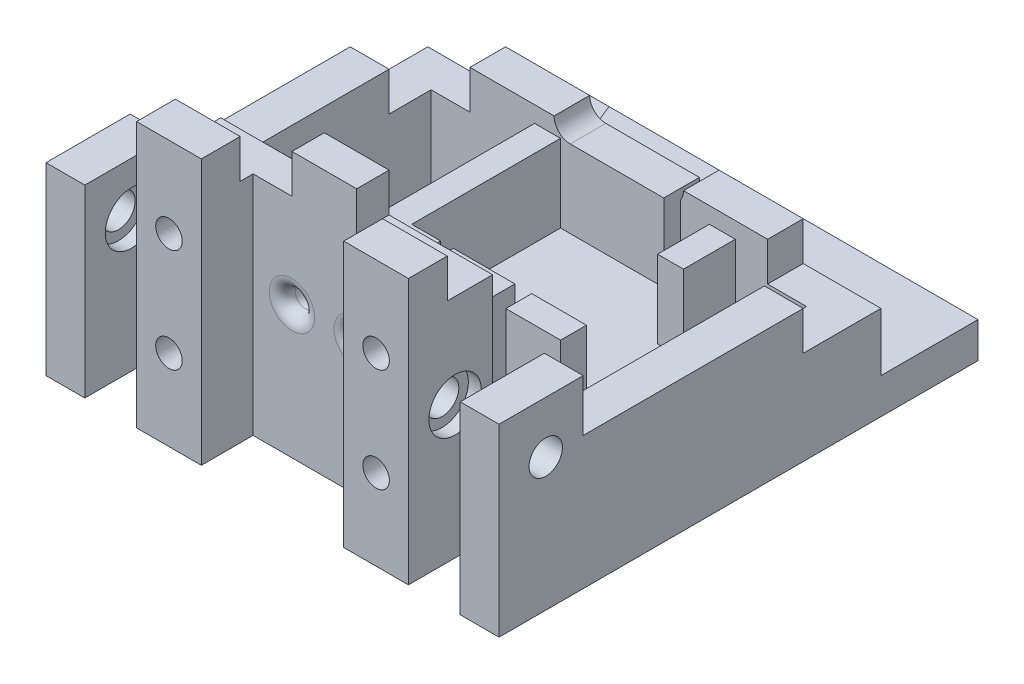
from build123d import *

# Parameters (mm, degrees)
BOSS_EXTRUDE1_DEPTH  = 20.5
SKETCH5_W            = 23
SKETCH5_H            = 23
BOSS_EXTRUDE3_DEPTH  = 6
BOSS_EXTRUDE6_DEPTH  = 18
SKETCH18_W           = 2.6
SKETCH18_H           = 4
SKETCH18_W_2         = 2
SKETCH18_W_3         = 4
SKETCH18_H_2         = 15
SKETCH18_H_3         = 5.5
CUT_EXTRUDE10_DEPTH  = 14.5
SKETCH8_W            = 6
SKETCH8_H            = 13
BOSS_EXTRUDE4_DEPTH  = 8
SKETCH7_R            = 2.575
CUT_EXTRUDE_X_DEPTH  = 6
SKETCH9_R            = 4.05
CUT_EXTRUDE4_DEPTH   = 2
SKETCH10_W           = 29
SKETCH10_H           = 13
BOSS_EXTRUDE5_DEPTH  = 28.5
SKETCH12_W           = 8
SKETCH12_H           = 13
CUT_EXTRUDE6_DEPTH   = 24
SKETCH13_R           = 2.575
CUT_EXTRUDE7_DEPTH   = 6
SKETCH14_R           = 4.05
CUT_EXTRUDE8_DEPTH   = 2
CUT_EXTRUDE21_REACH  = 61
SKETCH35_R           = 1.5
CUT_EXTRUDE22_REACH  = 30.5
FILLET1_R            = 2
BOSS_EXTRUDE7_DEPTH  = 12.5
SKETCH34_R           = 2.05
CUT_EXTRUDE20_DEPTH  = 10
SKETCH38_W           = 70
SKETCH38_H           = 5.5
BOSS_EXTRUDE8_DEPTH  = 15
BOSS_EXTRUDE9_DEPTH  = 7.5
CUT_EXTRUDE23_START  = -5.5
CUT_EXTRUDE23_DEPTH  = 5.5
BOSS_EXTRUDE10_DEPTH = 58
CUT_EXTRUDE24_REACH  = 76
SKETCH42_W           = 8
SKETCH42_H           = 4.5
BOSS_EXTRUDE11_START = -14
SKETCH43_W           = 10
SKETCH43_H           = 5
BOSS_EXTRUDE11_DEPTH = 42
BOSS_EXTRUDE12_REACH = 22
SKETCH44_W           = 42
SKETCH44_H           = 5
SKETCH45_W           = 12
SKETCH45_H           = 12
CUT_EXTRUDE25_DEPTH  = 6
CUT_EXTRUDE26_DEPTH  = 6


with BuildPart() as part:
    # Sketch1 → Boss-Extrude1 (new body)
    with BuildSketch(Plane(origin=(0, 0, 0), x_dir=(1, 0, 0), z_dir=(0, 1, 0))):
        Polygon((-29, 24), (-29, -29.5), (-35, -29.5), (-35, 29.5), (35, 29.5), (35, -29.5), (29, -29.5), (29, 24), align=None)
    extrude(amount=-BOSS_EXTRUDE1_DEPTH)



with BuildPart() as body_2:
    # Sketch5 → Boss-Extrude3 (new body)
    with BuildSketch(Plane(origin=(0, -20.5, 0), x_dir=(1, 0, 0), z_dir=(0, 1, 0))):
        with Locations((2.5, 12.5)):
            Rectangle(SKETCH5_W, SKETCH5_H)
    extrude(amount=BOSS_EXTRUDE3_DEPTH)


with BuildPart() as part_1:
    add(part.part)

    add(body_2.part)  # Boss-Extrude6 merges body 2
    # Sketch16 → Boss-Extrude6 (add)
    with BuildSketch(Plane.XZ.offset(20.5)):
        Polygon((18, -24), (14, -24), (14, -1), (-9, -1), (-9, -24), (-13, -24), (-13, 3), (18, 3), align=None)
    extrude(amount=-BOSS_EXTRUDE6_DEPTH)

    # Sketch18 → Cut-Extrude10 (cut)
    with BuildSketch(Plane(origin=(0, 0, 0), x_dir=(1, 0, 0), z_dir=(0, 1, 0))):
        with Locations((8.25, -1)):
            Rectangle(SKETCH18_W, SKETCH18_H)
        with Locations((-3.55, -1)):
            Rectangle(SKETCH18_W_2, SKETCH18_H)
        with Locations((16, 8.5)):
            Rectangle(SKETCH18_W_3, SKETCH18_H_2)
        with Locations((8.25, 26.75)):
            Rectangle(SKETCH18_W, SKETCH18_H_3)
    extrude(amount=-CUT_EXTRUDE10_DEPTH, mode=Mode.SUBTRACT)

    # Sketch8 → Boss-Extrude4 (add)
    with BuildSketch(Plane(origin=(0, 0, 0), x_dir=(1, 0, 0), z_dir=(0, 1, 0))):
        with Locations((32, -23)):
            Rectangle(SKETCH8_W, SKETCH8_H)
    boss_extrude4 = extrude(amount=BOSS_EXTRUDE4_DEPTH)

    # Sketch7 → Cut-Extrude x (cut)
    with BuildSketch(Plane(origin=(35, 0, 0), x_dir=(0, 0, -1), z_dir=(1, 0, 0))):
        with Locations((-22.291637032, 0)):
            Circle(SKETCH7_R)
    cut_extrude_x = extrude(amount=-CUT_EXTRUDE_X_DEPTH, mode=Mode.SUBTRACT)

    # Sketch9 → Cut-Extrude4 (cut)
    with BuildSketch(Plane(origin=(29, 0, 0), x_dir=(0, 0, -1), z_dir=(1, 0, 0))):
        with Locations((-22.291637032, 0)):
            Circle(SKETCH9_R)
    cut_extrude4 = extrude(amount=CUT_EXTRUDE4_DEPTH, mode=Mode.SUBTRACT)

    # Sketch10 → Boss-Extrude5 (add)
    with BuildSketch(Plane.XZ.offset(20.5)):
        with Locations((14.5, 23)):
            Rectangle(SKETCH10_W, SKETCH10_H)
    boss_extrude5 = extrude(amount=-BOSS_EXTRUDE5_DEPTH)

    # Sketch12 → Cut-Extrude6 (cut)
    with BuildSketch(Plane(origin=(0, 8, 0), x_dir=(1, 0, 0), z_dir=(0, 1, 0))):
        with Locations((25, -23)):
            Rectangle(SKETCH12_W, SKETCH12_H)
    cut_extrude6 = extrude(amount=-CUT_EXTRUDE6_DEPTH, mode=Mode.SUBTRACT)

    # Sketch13 → Cut-Extrude7 (cut)
    with BuildSketch(Plane(origin=(21, 0, 0), x_dir=(0, 0, -1), z_dir=(1, 0, 0))):
        with Locations((-22.291637032, 0)):
            Circle(SKETCH13_R)
    cut_extrude7 = extrude(amount=-CUT_EXTRUDE7_DEPTH, mode=Mode.SUBTRACT)

    # Sketch14 → Cut-Extrude8 (cut)
    with BuildSketch(Plane(origin=(21, 0, 0), x_dir=(0, 0, -1), z_dir=(1, 0, 0))):
        with Locations((-22.291637032, 0)):
            Circle(SKETCH14_R)
    cut_extrude8 = extrude(amount=-CUT_EXTRUDE8_DEPTH, mode=Mode.SUBTRACT)

    # Mirror1: Boss-Extrude4, Cut-Extrude x, Cut-Extrude4, Boss-Extrude5, Cut-Extrude6, Cut-Extrude7, Cut-Extrude8 across plane
    add(boss_extrude4.mirror(Plane(origin=(0, 0, 0), x_dir=(0, 0, 1), z_dir=(1, 0, 0))))
    add(cut_extrude_x.mirror(Plane(origin=(0, 0, 0), x_dir=(0, 0, 1), z_dir=(1, 0, 0))), mode=Mode.SUBTRACT)
    add(cut_extrude4.mirror(Plane(origin=(0, 0, 0), x_dir=(0, 0, 1), z_dir=(1, 0, 0))), mode=Mode.SUBTRACT)
    add(boss_extrude5.mirror(Plane(origin=(0, 0, 0), x_dir=(0, 0, 1), z_dir=(1, 0, 0))))
    add(cut_extrude6.mirror(Plane(origin=(0, 0, 0), x_dir=(0, 0, 1), z_dir=(1, 0, 0))), mode=Mode.SUBTRACT)
    add(cut_extrude7.mirror(Plane(origin=(0, 0, 0), x_dir=(0, 0, 1), z_dir=(1, 0, 0))), mode=Mode.SUBTRACT)
    add(cut_extrude8.mirror(Plane(origin=(0, 0, 0), x_dir=(0, 0, 1), z_dir=(1, 0, 0))), mode=Mode.SUBTRACT)

    # Sketch35 → Cut-Extrude21 (cut, up to next)
    with BuildSketch(Plane.XY.offset(29.5), mode=Mode.PRIVATE) as cut_extrude21_sk1:
        with Locations((-5, 0)):
            Circle(SKETCH35_R)
    cut_extrude21_tool1 = extrude(cut_extrude21_sk1.sketch, amount=-CUT_EXTRUDE21_REACH, mode=Mode.PRIVATE) & part_1.part
    add(cut_extrude21_tool1.solids().sort_by_distance((-5, 0, 29.5))[0], mode=Mode.SUBTRACT)
    # Sketch35 → Cut-Extrude21 (cut, up to next)
    with BuildSketch(Plane.XY.offset(29.5), mode=Mode.PRIVATE) as cut_extrude21_sk2:
        with Locations((5, 0)):
            Circle(SKETCH35_R)
    cut_extrude21_tool2 = extrude(cut_extrude21_sk2.sketch, amount=-CUT_EXTRUDE21_REACH, mode=Mode.PRIVATE) & part_1.part
    add(cut_extrude21_tool2.solids().sort_by_distance((5, 0, 29.5))[0], mode=Mode.SUBTRACT)

    # Sketch36 → Cut-Extrude22 (cut, up to next)
    with BuildSketch(Plane(origin=(0, 8, 0), x_dir=(1, 0, 0), z_dir=(0, 1, 0)), mode=Mode.PRIVATE) as cut_extrude22_sk1:
        Polygon((-5, -29.5), (5, -29.5), (11, -29.5), (11, -21.5), (-11, -21.5), (-11, -29.5), align=None)
    cut_extrude22_tool1 = extrude(cut_extrude22_sk1.sketch, amount=-CUT_EXTRUDE22_REACH, mode=Mode.PRIVATE) & part_1.part
    add(cut_extrude22_tool1.solids().sort_by_distance((0, 8, 25.5))[0], mode=Mode.SUBTRACT)

    # Fillet1
    fillet1_edges = [part_1.edges().sort_by_distance(p)[0] for p in [
        (-6.5, 0, 16.5),
        (3.5, 0, 16.5),
        (-6.5, 0, 21.5),
        (3.5, 0, 21.5),
    ]]
    fillet(fillet1_edges, radius=FILLET1_R)

    # Sketch37 → Boss-Extrude7 (add)
    with BuildSketch(Plane(origin=(0, 8, 0), x_dir=(1, 0, 0), z_dir=(0, 1, 0))):
        Polygon((-11, -21.5), (11, -21.5), (11, -29.5), (21, -29.5), (21, -16.5), (-21, -16.5), (-21, -29.5), (-11, -29.5), align=None)
    extrude(amount=BOSS_EXTRUDE7_DEPTH)

    # Sketch34 → Cut-Extrude20 (cut)
    with BuildSketch(Plane.XY.offset(29.5)):
        with Locations((16, -8)):
            Circle(SKETCH34_R)
        with Locations((16, 8)):
            Circle(SKETCH34_R)
        with Locations((-16, 8)):
            Circle(SKETCH34_R)
        with Locations((-16, -8)):
            Circle(SKETCH34_R)
    extrude(amount=-CUT_EXTRUDE20_DEPTH, mode=Mode.SUBTRACT)

    # Sketch38 → Boss-Extrude8 (add)
    with BuildSketch(Plane(origin=(0, 0, -29.5), x_dir=(-1, 0, 0), z_dir=(0, 0, -1))):
        with Locations((0, -17.75)):
            Rectangle(SKETCH38_W, SKETCH38_H)
    extrude(amount=BOSS_EXTRUDE8_DEPTH)

    # Sketch39 → Boss-Extrude9 (add)
    with BuildSketch(Plane(origin=(0, -15, 0), x_dir=(1, 0, 0), z_dir=(0, 1, 0))):
        Polygon((11.5, 29.5), (14.5, 37), (-14.5, 37), (-11.5, 29.5), align=None)
    extrude(amount=BOSS_EXTRUDE9_DEPTH)

    # Sketch40 → Cut-Extrude23 (cut)
    with BuildSketch(Plane(origin=(0, 0, -29.5), x_dir=(-1, 0, 0), z_dir=(0, 0, -1)).offset(CUT_EXTRUDE23_START)):
        with BuildLine():
            Line((-7.5, 2.5), (7.5, 2.5))
            ThreePointArc((7.5, 2.5), (10, 0), (7.5, -2.5))
            Line((7.5, -2.5), (-7.5, -2.5))
            ThreePointArc((-7.5, -2.5), (-10, 0), (-7.5, 2.5))
        make_face()
    extrude(amount=CUT_EXTRUDE23_DEPTH, mode=Mode.SUBTRACT)

    # Sketch41 → Boss-Extrude10 (add)
    with BuildSketch(Plane.ZY.offset(-29)):
        Polygon((-0.5, -20.5), (9.5, -20.5), (9.5, -17.5), (6.5, -15.5), (2.5, -15.5), (-0.5, -18.5), align=None)
    extrude(amount=BOSS_EXTRUDE10_DEPTH)

    # Sketch42 → Cut-Extrude24 (cut, up to next)
    with BuildSketch(Plane.XY.offset(29.5), mode=Mode.PRIVATE) as cut_extrude24_sk1:
        with Locations((25, -18.25)):
            Rectangle(SKETCH42_W, SKETCH42_H)
    cut_extrude24_tool1 = extrude(cut_extrude24_sk1.sketch, amount=-CUT_EXTRUDE24_REACH, mode=Mode.PRIVATE) & part_1.part
    add(cut_extrude24_tool1.solids().sort_by_distance((25, -18.25, 29.5))[0], mode=Mode.SUBTRACT)
    # Sketch42 → Cut-Extrude24 (cut, up to next)
    with BuildSketch(Plane.XY.offset(29.5), mode=Mode.PRIVATE) as cut_extrude24_sk2:
        with Locations((-25, -18.25)):
            Rectangle(SKETCH42_W, SKETCH42_H)
    cut_extrude24_tool2 = extrude(cut_extrude24_sk2.sketch, amount=-CUT_EXTRUDE24_REACH, mode=Mode.PRIVATE) & part_1.part
    add(cut_extrude24_tool2.solids().sort_by_distance((-25, -18.25, 29.5))[0], mode=Mode.SUBTRACT)

    # Sketch43 → Boss-Extrude11 (add)
    with BuildSketch(Plane(origin=(35, 0, 0), x_dir=(0, 0, -1), z_dir=(1, 0, 0)).offset(BOSS_EXTRUDE11_START)):
        with Locations((-4.5, -18)):
            Rectangle(SKETCH43_W, SKETCH43_H)
    extrude(amount=-BOSS_EXTRUDE11_DEPTH)

    # Sketch44 → Boss-Extrude12 (add, up to next)
    with BuildSketch(Plane.XY.offset(9.5), mode=Mode.PRIVATE) as boss_extrude12_sk1:
        with Locations((0, -18)):
            Rectangle(SKETCH44_W, SKETCH44_H)
    boss_extrude12_tool1 = extrude(boss_extrude12_sk1.sketch, amount=BOSS_EXTRUDE12_REACH, mode=Mode.PRIVATE) - part_1.part
    add(boss_extrude12_tool1.solids().sort_by_distance((0, -18, 9.5))[0])

    # Sketch45 → Cut-Extrude25 (cut)
    with BuildSketch(Plane(origin=(0, 0, 0), x_dir=(1, 0, 0), z_dir=(0, 1, 0))):
        with Locations((29, 23.5)):
            Rectangle(SKETCH45_W, SKETCH45_H)
        with Locations((-29, 23.5)):
            Rectangle(SKETCH45_W, SKETCH45_H)
    extrude(amount=-CUT_EXTRUDE25_DEPTH, mode=Mode.SUBTRACT)

    # Sketch46 → Cut-Extrude26 (cut)
    with BuildSketch(Plane(origin=(0, 20.5, 0), x_dir=(1, 0, 0), z_dir=(0, 1, 0))):
        Polygon((-5, -21.5), (-5, -16.5), (-21, -16.5), (-21, -23.5), (-11, -23.5), (-11, -21.5), align=None)
        Polygon((5, -21.5), (5, -16.5), (21, -16.5), (21, -23.5), (11, -23.5), (11, -21.5), align=None)
    extrude(amount=-CUT_EXTRUDE26_DEPTH, mode=Mode.SUBTRACT)


solid = part_1.part
